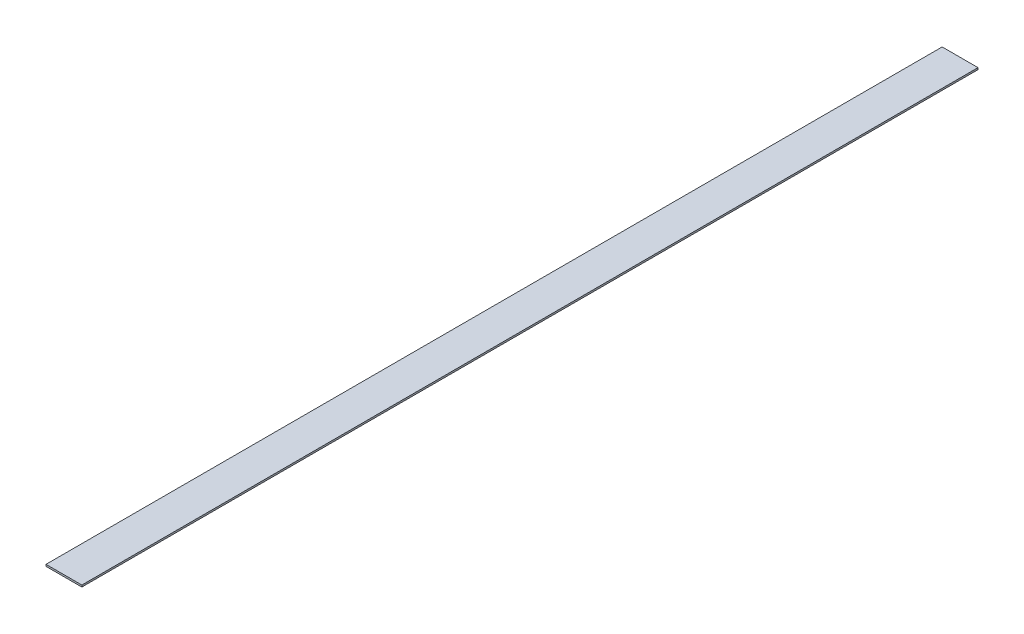
from build123d import *

# Parameters (mm, degrees)
ESQUISSE1_W        = 20
ESQUISSE1_H        = 500
BOSS_EXTRU_1_DEPTH = 1


with BuildPart() as part:
    # Esquisse1 → Boss.-Extru.1 (new body)
    with BuildSketch(Plane(origin=(0, 0, 0), x_dir=(1, 0, 0), z_dir=(0, 1, 0))):
        Rectangle(ESQUISSE1_W, ESQUISSE1_H)
    extrude(amount=BOSS_EXTRU_1_DEPTH)


solid = part.part
